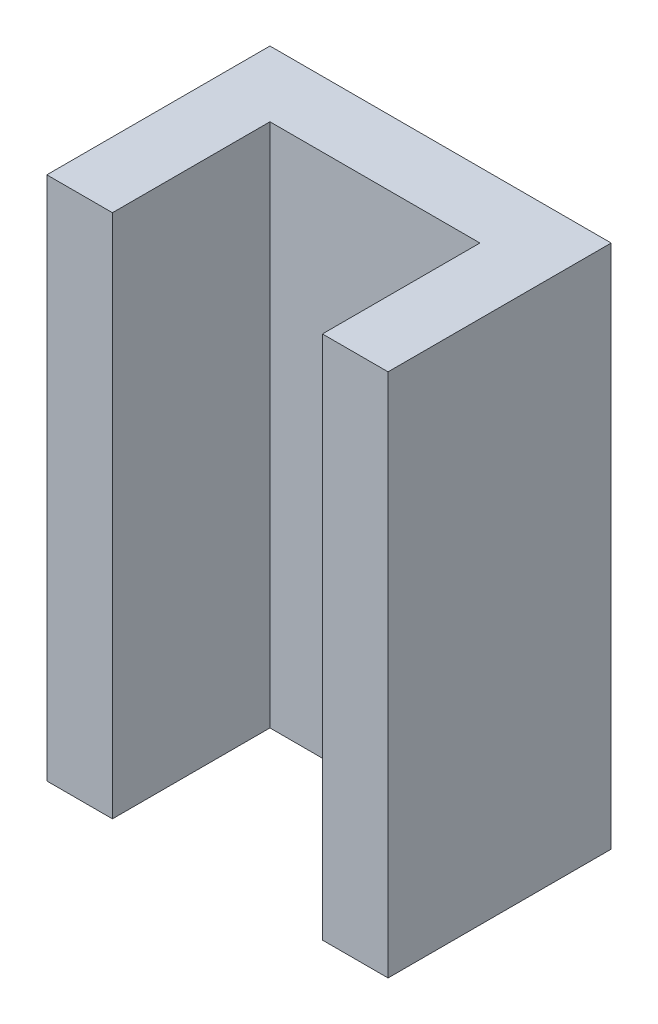
from build123d import *

# Parameters (mm, degrees)
BOSS_EXTRUDE1_DEPTH = 20


with BuildPart() as part:
    # Sketch1 → Boss-Extrude1 (new body)
    with BuildSketch(Plane(origin=(0, 0, 0), x_dir=(1, 0, 0), z_dir=(0, 1, 0))):
        Polygon((0, 0), (0, 8.5), (13, 8.5), (13, 0), (10.5, 0), (10.5, 6), (2.5, 6), (2.5, 0), align=None)
    extrude(amount=BOSS_EXTRUDE1_DEPTH)


solid = part.part
